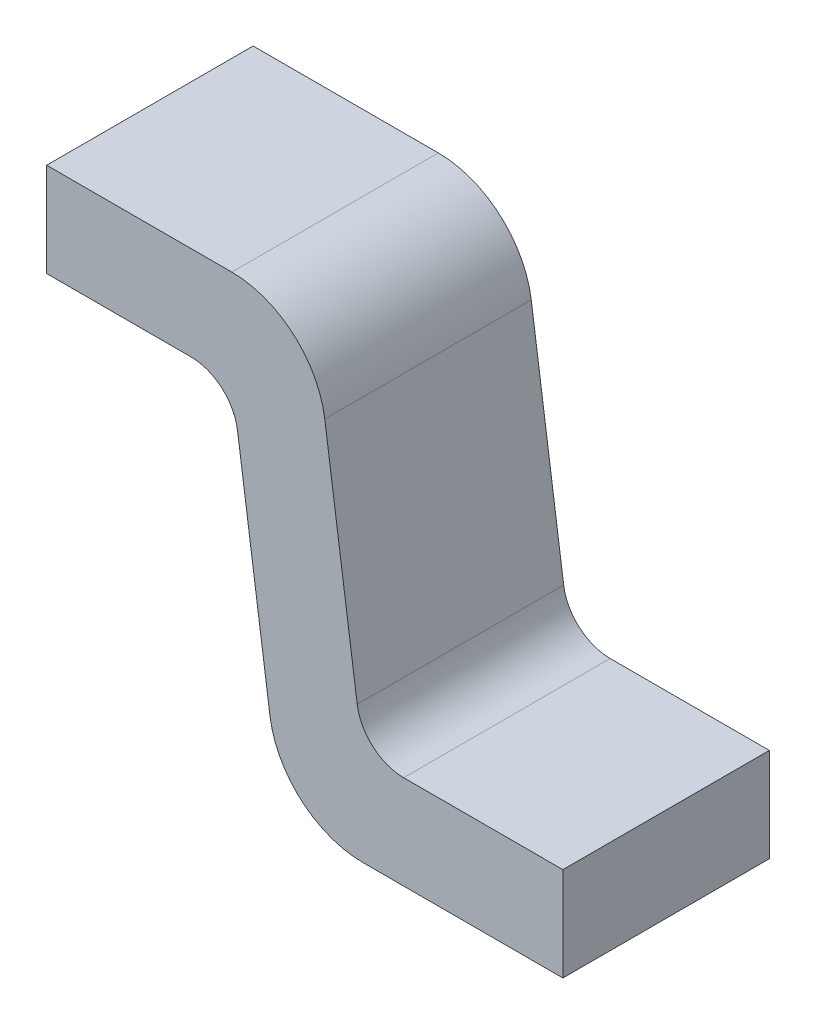
from build123d import *

# Parameters (mm, degrees)
EXTRUDE_1_DEPTH      = 0.22
EXTRUDE_1_DEPTH_BACK = 0.22


with BuildPart() as part:
    # Эскиз1 → Бобышка-Вытянуть1 (new, two sides: drawn at the far end of the back side and taken through both)
    with BuildSketch(Plane.XY.offset(-EXTRUDE_1_DEPTH_BACK)):
        with BuildLine():
            Line((0.673857348, 0), (1.1, 0))
            Line((1.1, 0), (1.1, 0.2))
            Line((1.1, 0.2), (0.760786021, 0.2))
            ThreePointArc((0.760786021, 0.2), (0.695180118, 0.224529042), (0.661759214, 0.28608269))
            Line((0.661759214, 0.28608269), (0.592647988, 0.77783462))
            ThreePointArc((0.592647988, 0.77783462), (0.52580618, 0.900941916), (0.394594374, 0.95))
            Line((0.394594374, 0.95), (0, 0.95))
            Line((0, 0.95), (0, 0.75))
            Line((0, 0.75), (0.3076657, 0.75))
            ThreePointArc((0.3076657, 0.75), (0.373271603, 0.725470958), (0.406692507, 0.66391731))
            Line((0.406692507, 0.66391731), (0.475803734, 0.17216538))
            ThreePointArc((0.475803734, 0.17216538), (0.542645542, 0.049058084), (0.673857348, 0))
        make_face()
    extrude(amount=EXTRUDE_1_DEPTH + EXTRUDE_1_DEPTH_BACK)


solid = part.part
